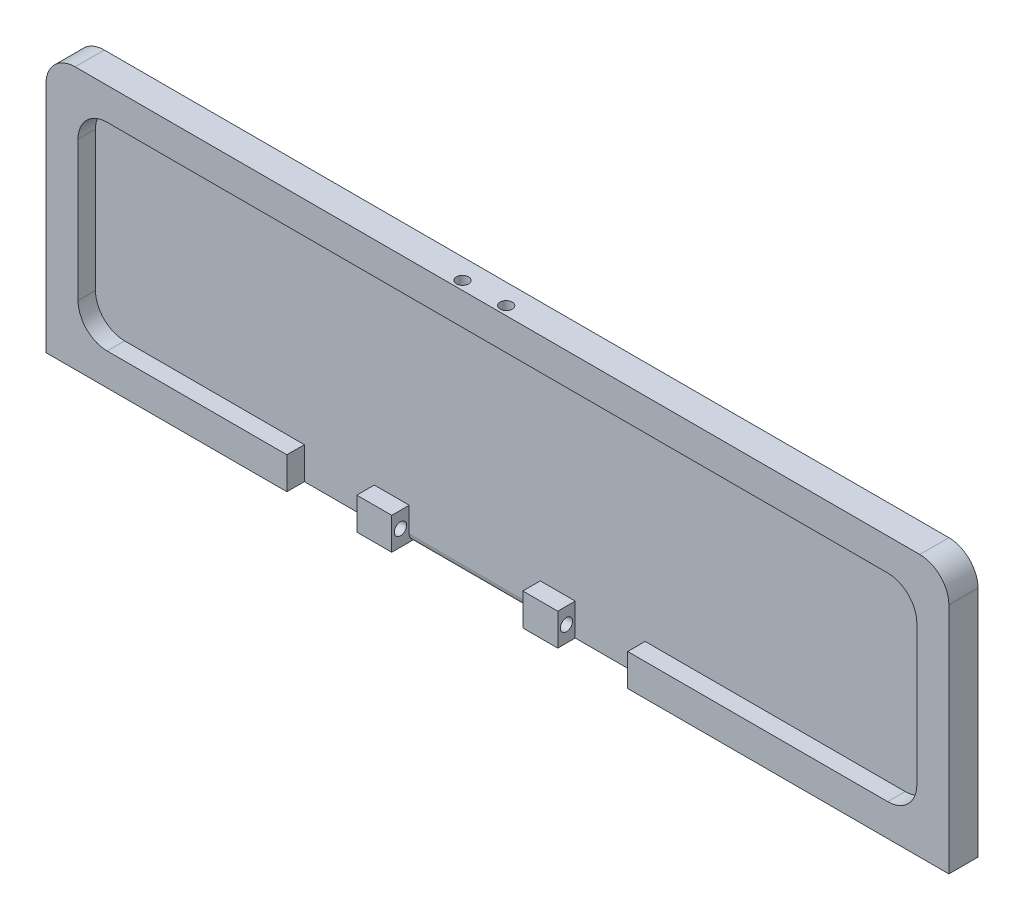
from build123d import *

# Parameters (mm, degrees)
SKETCH_1_W                  = 155
SKETCH_1_H                  = 45
EXTRUDE_1_DEPTH             = 5
SKETCH_2_W                  = 144
SKETCH_2_H                  = 34
CUT_EXTRUDE_1_DEPTH         = 3
FILLET_1_R                  = 5
FILLET_2_R                  = 5
SKETCH_7_W                  = 22.5
SKETCH_7_H                  = 5.5
CUT_EXTRUDE_2_DEPTH         = 3
FILLET_7_R                  = 1.2
SKETCH_9_W                  = 12
SKETCH_9_H                  = 5.5
CUT_EXTRUDE_3_DEPTH         = 3
HOLE_WIZARD_2_1_2_1_2_D     = 2.1
HOLE_WIZARD_2_1_2_1_2_DEPTH = 13.2
HOLE_WIZARD_2_1_2_1_2_TIP   = 0.63090365
SKETCH_15_W                 = 12
SKETCH_15_H                 = 5.5
CUT_EXTRUDE_4_DEPTH         = 3


with BuildPart() as part:
    # 草图1 → 凸台-拉伸1 (new body)
    with BuildSketch(Plane.XY):
        Rectangle(SKETCH_1_W, SKETCH_1_H)
    extrude(amount=EXTRUDE_1_DEPTH)

    # 草图2 → 切除-拉伸1 (cut)
    with BuildSketch(Plane.XY.offset(5)):
        Rectangle(SKETCH_2_W, SKETCH_2_H)
    extrude(amount=-CUT_EXTRUDE_1_DEPTH, mode=Mode.SUBTRACT)

    # 圆角1
    fillet_1_edges = [part.edges().sort_by_distance(p)[0] for p in [
        (-77.5, 22.5, 2.5),
        (77.5, 22.5, 2.5),
    ]]
    fillet(fillet_1_edges, radius=FILLET_1_R)

    # 圆角2
    fillet_2_edges = [part.edges().sort_by_distance(p)[0] for p in [
        (-72, -17, 3.5),
        (-72, 17, 3.5),
        (72, 17, 3.5),
        (72, -17, 3.5),
    ]]
    fillet(fillet_2_edges, radius=FILLET_2_R)

    # 草图7 → 切除-拉伸2 (cut)
    with BuildSketch(Plane.XY.offset(5)):
        with Locations((-6.895727583, -19.75)):
            Rectangle(SKETCH_7_W, SKETCH_7_H)
    extrude(amount=-CUT_EXTRUDE_2_DEPTH, mode=Mode.SUBTRACT)

    # 圆角7
    fillet_7_edges = [part.edges().sort_by_distance(p)[0] for p in [
        (-6.895727583, -22.5, 2),
    ]]
    fillet(fillet_7_edges, radius=FILLET_7_R)

    # 草图9 → 切除-拉伸3 (cut)
    with BuildSketch(Plane.XY.offset(5)):
        with Locations((16.354272417, -19.75)):
            Rectangle(SKETCH_9_W, SKETCH_9_H)
    extrude(amount=-CUT_EXTRUDE_3_DEPTH, mode=Mode.SUBTRACT)

    # 草图11 → Ø2.1 (2.1) 直径孔1 (revolve, cut)
    with BuildSketch(Plane(origin=(10.354272417, -19.75, 3.5), x_dir=(0, 0, -1), z_dir=(0, 1, 0))):
        Polygon((0, 0), (0, 36.63090365), (1.05, 36), (1.05, 0), align=None)
    revolve(axis=Axis((16.704272417, -19.75, 3.5), (-1, 0, 0)), mode=Mode.SUBTRACT)

    # Ø2.1 (2.1) 直径孔2
    with Locations(Plane(origin=(0, 22.5, 0), x_dir=(1, 0, 0), z_dir=(0, 1, 0))):
        with Locations((0, -3.5), (-7.5, -3.5)):
            Hole(HOLE_WIZARD_2_1_2_1_2_D / 2, depth=HOLE_WIZARD_2_1_2_1_2_DEPTH)
            with Locations((0, 0, -(HOLE_WIZARD_2_1_2_1_2_DEPTH + HOLE_WIZARD_2_1_2_1_2_TIP / 2))):  # 118° drill point
                Cone(0, HOLE_WIZARD_2_1_2_1_2_D / 2, HOLE_WIZARD_2_1_2_1_2_TIP, mode=Mode.SUBTRACT)

    # 草图15 → 切除-拉伸4 (cut)
    with BuildSketch(Plane.XY.offset(5)):
        with Locations((-30.145727583, -19.75)):
            Rectangle(SKETCH_15_W, SKETCH_15_H)
    extrude(amount=-CUT_EXTRUDE_4_DEPTH, mode=Mode.SUBTRACT)


solid = part.part
